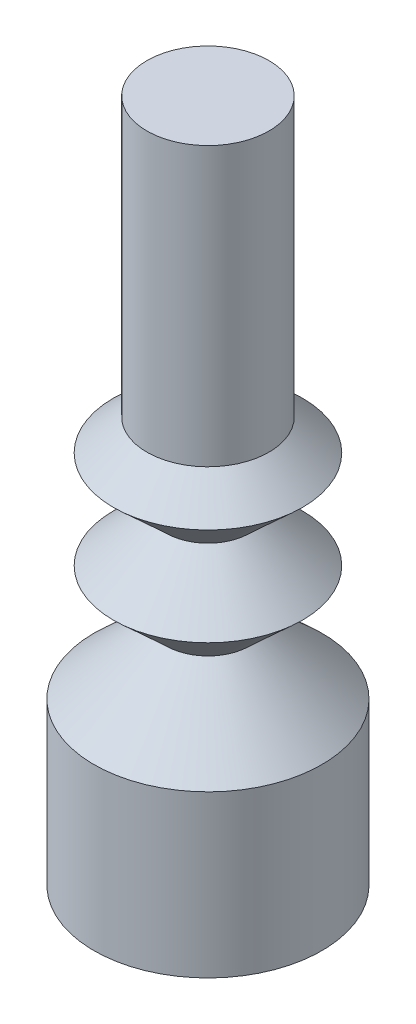
from build123d import *


with BuildPart() as part:
    # Sketch1 → Revolve1 (revolve)
    with BuildSketch(Plane.XY):
        Polygon((0, 8.5), (1.875, 8.5), (1.875, 4.5), (1.875, -0.04728904), (2.90710354, -1), (1.28210354, -2.5), (2.90710354, -4), (1.28210354, -5.5), (3.5, -7.54728904), (3.5, -12.5), (0, -12.5), align=None)
    revolve(axis=Axis((0, 12.5, 0), (0, -1, 0)))


solid = part.part
